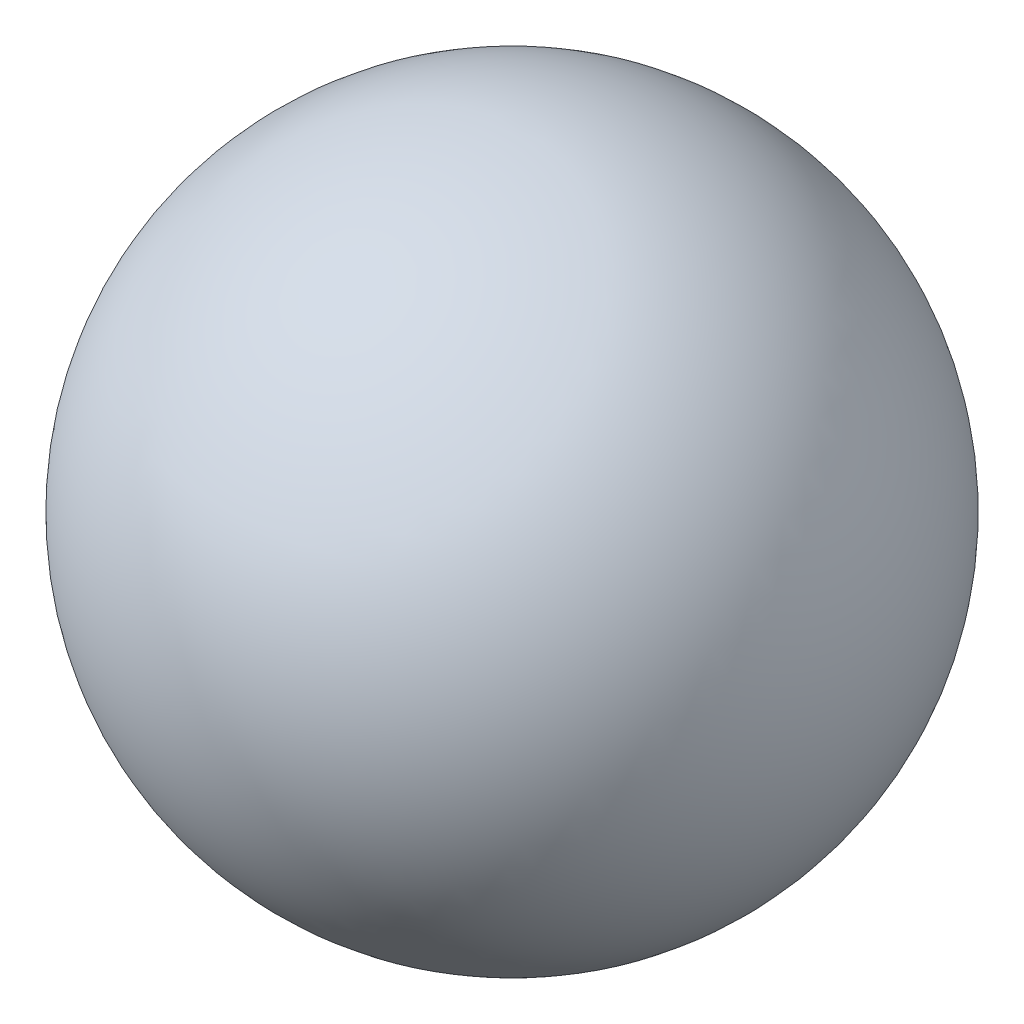
from build123d import *


with BuildPart() as part:
    # Sketch1 → Revolve1 (revolve)
    with BuildSketch(Plane.XY):
        with BuildLine():
            Line((0, 1.27), (0, -1.27))
            ThreePointArc((0, -1.27), (1.27, 0), (0, 1.27))
        make_face()
    revolve(axis=Axis((0, 5.811212121, 0), (0, -1, 0)))


solid = part.part
